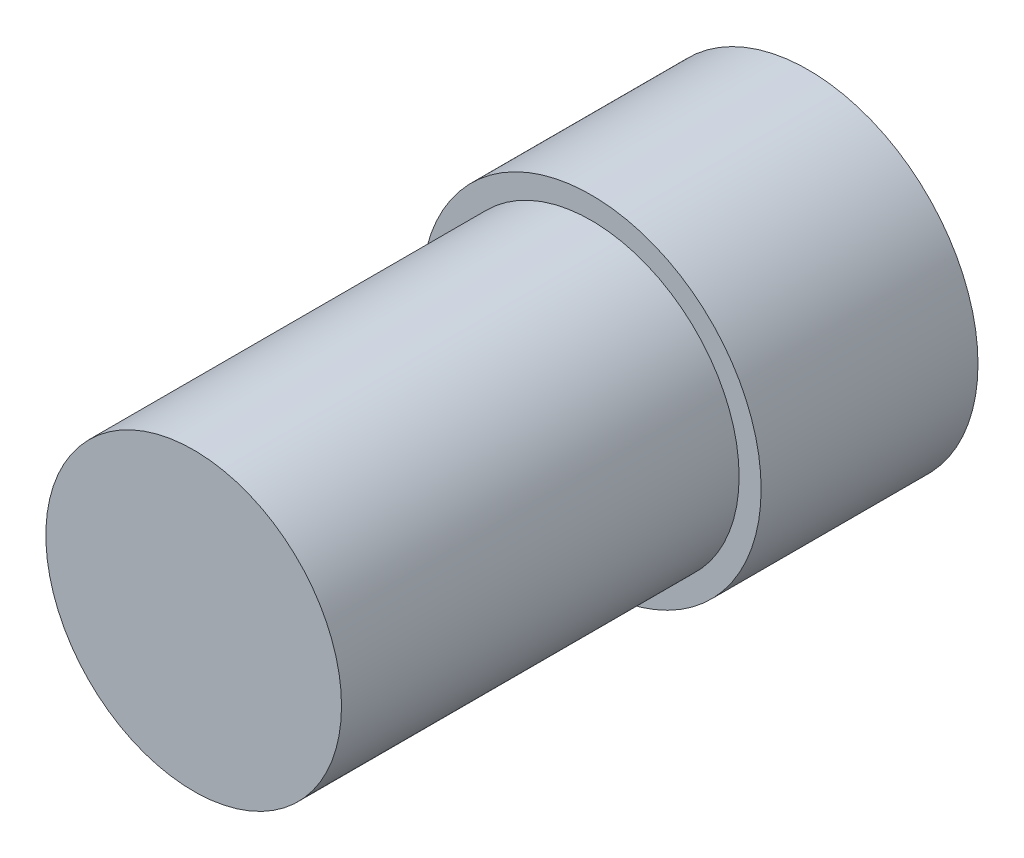
from build123d import *

# Parameters (mm, degrees)
SKETCH1_R           = 4.699
BOSS_EXTRUDE1_DEPTH = 6
SKETCH3_R           = 4.09
BOSS_EXTRUDE2_DEPTH = 11


with BuildPart() as part:
    # Sketch1 → Boss-Extrude1 (new body)
    with BuildSketch(Plane.XY):
        Circle(SKETCH1_R)
    extrude(amount=BOSS_EXTRUDE1_DEPTH)

    # Sketch3 → Boss-Extrude2 (add)
    with BuildSketch(Plane.XY.offset(6)):
        Circle(SKETCH3_R)
    extrude(amount=BOSS_EXTRUDE2_DEPTH)


solid = part.part
